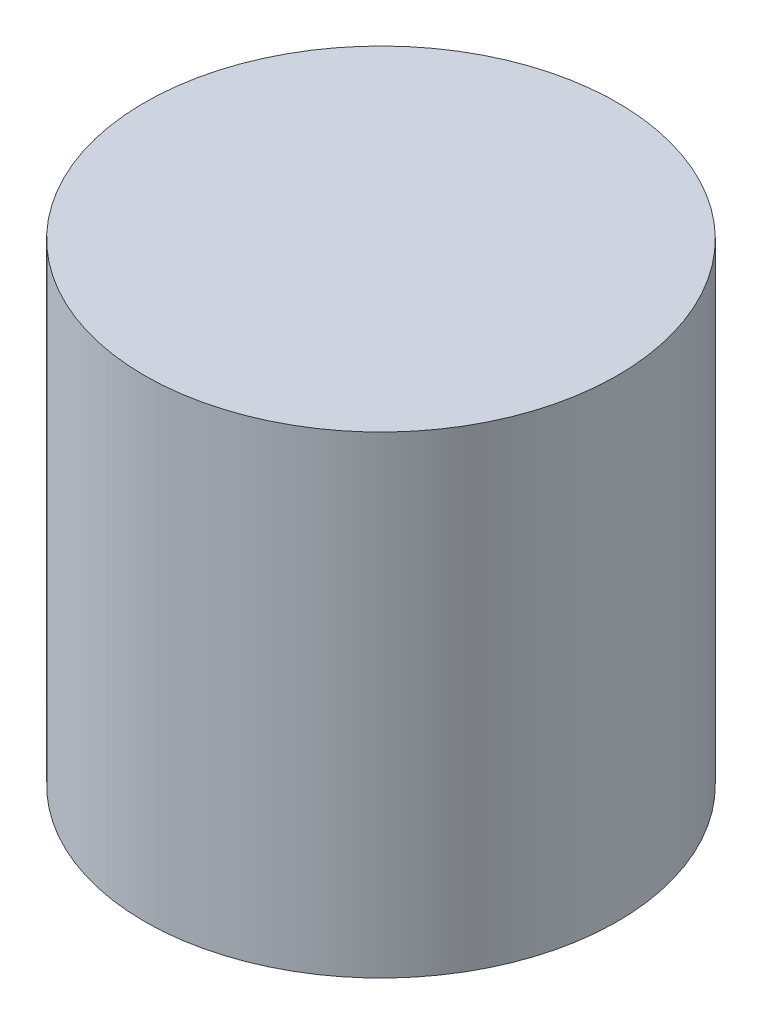
from build123d import *

# Parameters (mm, degrees)
SKETCH1_R           = 25.4
BOSS_EXTRUDE1_DEPTH = 50.8


with BuildPart() as part:
    # Sketch1 → Boss-Extrude1 (new body)
    with BuildSketch(Plane(origin=(0, 0, 0), x_dir=(1, 0, 0), z_dir=(0, 1, 0))):
        Circle(SKETCH1_R)
    extrude(amount=BOSS_EXTRUDE1_DEPTH)


solid = part.part
